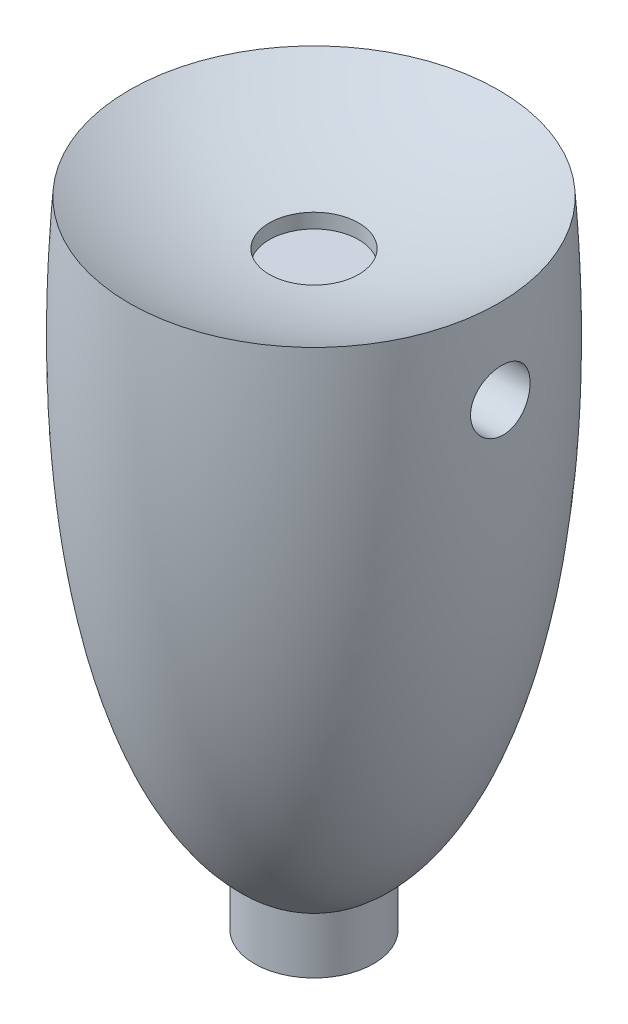
from build123d import *

# Parameters (mm, degrees)
DOME2_FACE_RADIUS               = 3.1
DOME2_HEIGHT                    = 0.8
SKETCH6_R                       = 0.500000006
CUT_EXTRUDE2_DEPTH              = 1
SKETCH7_R                       = 0.75
CUT_EXTRUDE3_DEPTH              = 1
BOSS_EXTRUDE1_REACH             = 12.152
SKETCH9_R                       = 1
SKETCH9_R_2                     = 0.45
BOSS_EXTRUDE1_DIRECTION_2_DEPTH = 0.5


with BuildPart() as part:
    # Sketch2 → Revolve2 (revolve)
    with BuildSketch(Plane.XY):
        with BuildLine():
            Line((0, 0), (3.1, 0))
            add(Edge.make_bspline(
                [(0, -10.151978408), (2.177642547, -9.857333884), (3.515065362, -5.793498011), (3.1, 0)],
                knots=[0, 0, 0, 0, 1, 1, 1, 1], degree=3))
            Line((0, -10.151978408), (0, 0))
        make_face()
    revolve(axis=Axis((0, -10.151978408, 0), (0, 1, 0)))

    # Dome2: a dome of height H over a round flat face of radius A is a cap of a sphere of radius (A * A + H * H) / (2 * H)
    dome2_r = (DOME2_FACE_RADIUS * DOME2_FACE_RADIUS + DOME2_HEIGHT * DOME2_HEIGHT) / (2 * DOME2_HEIGHT)
    dome2_base = Plane((0, 0, 0), z_dir=(0, -1, 0))
    with Locations(dome2_base.offset(DOME2_HEIGHT - dome2_r)):
        dome2_ball = Sphere(dome2_r, mode=Mode.PRIVATE)
    add(split(dome2_ball, bisect_by=dome2_base, keep=Keep.TOP, mode=Mode.PRIVATE), mode=Mode.SUBTRACT)

    # Sketch6 → Cut-Extrude2 (cut, symmetric)
    with BuildSketch(Plane(origin=(3.16696636, 0, 0), x_dir=(0, 0, -1), z_dir=(1, 0, 0))):
        with Locations((0, -1.377313707)):
            Circle(SKETCH6_R)
    cut_extrude2 = extrude(amount=CUT_EXTRUDE2_DEPTH, both=True, mode=Mode.SUBTRACT)

    # Mirror1: Cut-Extrude2 across plane
    add(cut_extrude2.mirror(Plane(origin=(0, 0, 0), x_dir=(0, 0, 1), z_dir=(1, 0, 0))), mode=Mode.SUBTRACT)

    # Sketch7 → Cut-Extrude3 (cut)
    with BuildSketch(Plane(origin=(0, 0, 0), x_dir=(1, 0, 0), z_dir=(0, 1, 0))):
        Circle(SKETCH7_R)
    extrude(amount=-CUT_EXTRUDE3_DEPTH, mode=Mode.SUBTRACT)

    # Sketch9 → Boss-Extrude1 (add, up to next)
    with BuildSketch(Plane(origin=(0, -10.151978408, 0), x_dir=(1, 0, 0), z_dir=(0, 1, 0)), mode=Mode.PRIVATE) as boss_extrude1_sk1:
        Circle(SKETCH9_R)
        Circle(SKETCH9_R_2, mode=Mode.SUBTRACT)
    boss_extrude1_tool1 = extrude(boss_extrude1_sk1.sketch, amount=BOSS_EXTRUDE1_REACH, mode=Mode.PRIVATE) - part.part
    add(boss_extrude1_tool1.solids().sort_by_distance((-0.971716, -10.151978, 0))[0])

    # Sketch9 → Boss-Extrude1 direction 2 (add)
    with BuildSketch(Plane(origin=(0, -10.151978408, 0), x_dir=(1, 0, 0), z_dir=(0, 1, 0))):
        Circle(SKETCH9_R)
        Circle(SKETCH9_R_2, mode=Mode.SUBTRACT)
    extrude(amount=-BOSS_EXTRUDE1_DIRECTION_2_DEPTH)


solid = part.part
